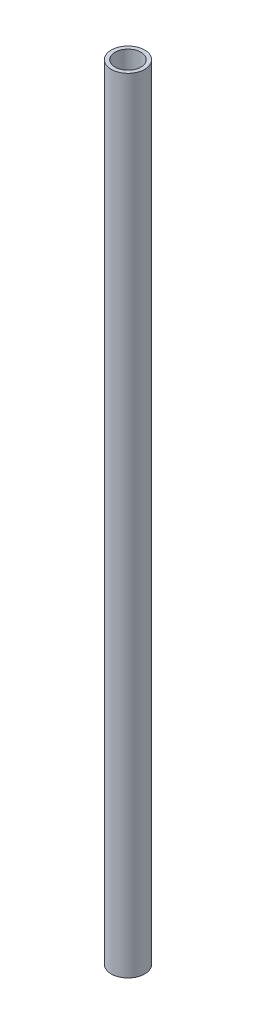
from build123d import *

# Parameters (mm, degrees)
SKETCH1_R           = 5.95
SKETCH1_R_2         = 4.6
BOSS_EXTRUDE1_DEPTH = 278.5


with BuildPart() as part:
    # Sketch1 → Boss-Extrude1 (new body)
    with BuildSketch(Plane(origin=(0, 0, 0), x_dir=(1, 0, 0), z_dir=(0, 1, 0))):
        Circle(SKETCH1_R)
        Circle(SKETCH1_R_2, mode=Mode.SUBTRACT)
    extrude(amount=BOSS_EXTRUDE1_DEPTH)


solid = part.part
